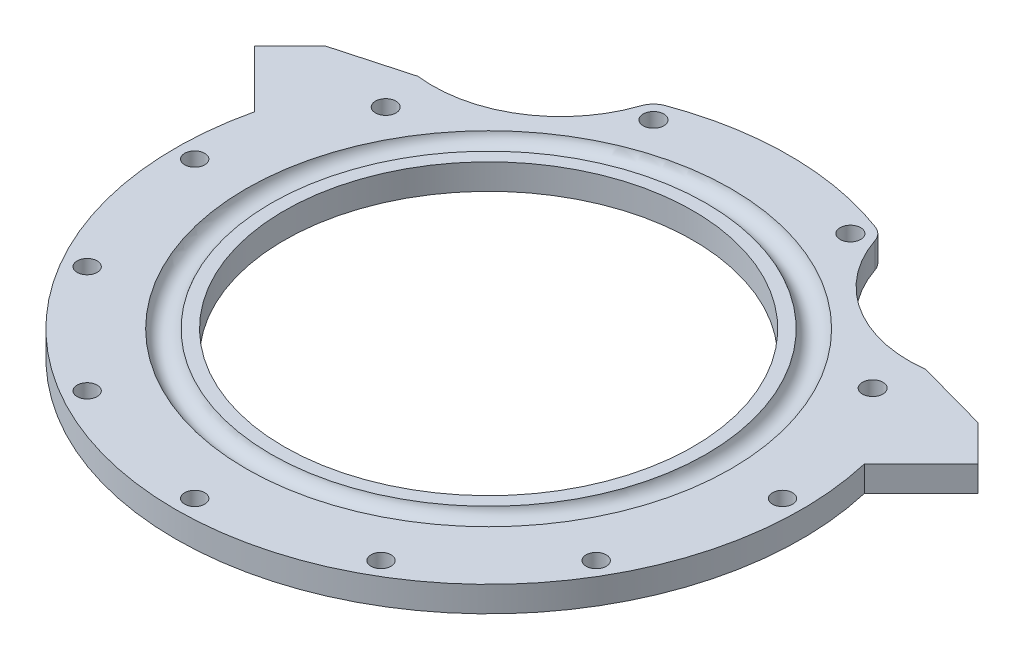
from build123d import *

# Parameters (mm, degrees)
SKETCH1_R           = 63.5
SKETCH1_R_2         = 50.8
BOSS_EXTRUDE1_DEPTH = 3.175
SKETCH2_R           = 3.175
SKETCH3_R           = 77.7875
SKETCH3_R_2         = 63.5
BOSS_EXTRUDE2_DEPTH = 6.35
SKETCH4_R           = 2.4892
CUT_EXTRUDE1_DEPTH  = 7.35
CIRPATTERN1_COUNT   = 12
BOSS_EXTRUDE3_DEPTH = 6.35
SKETCH6_R           = 31.75
CUT_EXTRUDE2_DEPTH  = 7.35
SKETCH7_R           = 2.5527
CUT_EXTRUDE3_DEPTH  = 7.35
BOSS_EXTRUDE4_DEPTH = 6.35
CUT_EXTRUDE4_DEPTH  = 7.35


with BuildPart() as part:
    # Sketch1 → Boss-Extrude1 (new body, symmetric)
    with BuildSketch(Plane(origin=(0, 0, 0), x_dir=(1, 0, 0), z_dir=(0, 1, 0))):
        Circle(SKETCH1_R)
        Circle(SKETCH1_R_2, mode=Mode.SUBTRACT)
    extrude(amount=BOSS_EXTRUDE1_DEPTH, both=True)

    # Sketch2 → Cut-Revolve1 (revolve, cut)
    with BuildSketch(Plane.XY):
        with Locations((57.15, 3.81)):
            Circle(SKETCH2_R)
    revolve(axis=Axis((0, 0, 0), (0, 1, 0)), mode=Mode.SUBTRACT)

    # Sketch3 → Boss-Extrude2 (add, through all)
    with BuildSketch(Plane.XZ.offset(3.175)):
        Circle(SKETCH3_R)
        Circle(SKETCH3_R_2, mode=Mode.SUBTRACT)
    extrude(amount=-BOSS_EXTRUDE2_DEPTH)

    # Sketch4 → Cut-Extrude1 (cut, through all)
    with BuildSketch(Plane(origin=(0, 3.175, 0), x_dir=(1, 0, 0), z_dir=(0, 1, 0))):
        with Locations((0, -73.025)):
            Circle(SKETCH4_R)
    cut_extrude1 = extrude(amount=-CUT_EXTRUDE1_DEPTH, mode=Mode.SUBTRACT)

    # CirPattern1: Cut-Extrude1 ×12 about axis, 5 skipped
    cirpattern1_axis = Axis((0, 0, 0), (0, 1, 0))
    add([cut_extrude1.rotate(cirpattern1_axis, i * 360 / CIRPATTERN1_COUNT) for i in range(1, CIRPATTERN1_COUNT) if i not in (4, 5, 6, 7, 8)], mode=Mode.SUBTRACT)

    # Sketch5 → Boss-Extrude3 (add, through all)
    with BuildSketch(Plane(origin=(0, 3.175, 0), x_dir=(1, 0, 0), z_dir=(0, 1, 0))):
        with BuildLine():
            Line((74.895357071, 21.013820344), (87.737123324, 33.855586598))
            Line((87.737123324, 33.855586598), (81.001931233, 40.590778688))
            Line((81.001931233, 40.590778688), (71.363979938, 30.952827393))
            ThreePointArc((71.363979938, 30.952827393), (73.298324543, 26.043248173), (74.895357071, 21.013820344))
        make_face()
        with BuildLine():
            Line((-71.363979938, 30.952827393), (-81.001931233, 40.590778688))
            Line((-81.001931233, 40.590778688), (-87.737123324, 33.855586598))
            Line((-87.737123324, 33.855586598), (-74.895357071, 21.013820344))
            ThreePointArc((-74.895357071, 21.013820344), (-73.298324543, 26.043248173), (-71.363979938, 30.952827393))
        make_face()
    extrude(amount=-BOSS_EXTRUDE3_DEPTH)

    # Sketch6 → Cut-Extrude2 (cut, through all)
    with BuildSketch(Plane(origin=(0, 3.175, 0), x_dir=(1, 0, 0), z_dir=(0, 1, 0))):
        with Locations((59.128754095, 77.058092601)):
            Circle(SKETCH6_R)
    cut_extrude2 = extrude(amount=-CUT_EXTRUDE2_DEPTH, mode=Mode.SUBTRACT)

    # Sketch7 → Cut-Extrude3 (cut, through all)
    with BuildSketch(Plane(origin=(0, 3.175, 0), x_dir=(1, 0, 0), z_dir=(0, 1, 0))):
        with Locations((-24.461985581, 65.426552419)):
            Circle(SKETCH7_R)
        with Locations((-60.491874454, 34.925)):
            Circle(SKETCH7_R)
        with Locations((24.461985581, 65.426552419)):
            Circle(SKETCH7_R)
        with Locations((60.491874454, 34.925)):
            Circle(SKETCH7_R)
    extrude(amount=-CUT_EXTRUDE3_DEPTH, mode=Mode.SUBTRACT)

    # Sketch9 → Boss-Extrude4 (add, through all)
    with BuildSketch(Plane(origin=(0, 3.175, 0), x_dir=(1, 0, 0), z_dir=(0, 1, 0))):
        Polygon((75.767612718, 17.611474078), (73.630311762, 19.748775035), (87.737123324, 33.855586598), (89.874424281, 31.718285641), align=None)
        Polygon((81.001931233, 40.590778688), (63.054974858, 45.551787033), (71.363979938, 30.952827393), align=None)
    boss_extrude4 = extrude(amount=-BOSS_EXTRUDE4_DEPTH)

    # Mirror1: Cut-Extrude2, Boss-Extrude4 across plane
    add(cut_extrude2.mirror(Plane(origin=(0, 0, 0), x_dir=(0, 0, 1), z_dir=(1, 0, 0))), mode=Mode.SUBTRACT)
    add(boss_extrude4.mirror(Plane(origin=(0, 0, 0), x_dir=(0, 0, 1), z_dir=(1, 0, 0))))

    # Sketch8 → Cut-Extrude4 (cut, through all)
    with BuildSketch(Plane.XZ.offset(3.175)):
        with BuildLine():
            ThreePointArc((-29.027902052, -66.958527944), (-27.924980023, -68.773522948), (-26.148609279, -69.937632415))
            ThreePointArc((-26.148609279, -69.937632415), (0, -74.666071244), (26.148609279, -69.937632415))
            ThreePointArc((26.148609279, -69.937632415), (27.924980023, -68.773522948), (29.027902052, -66.958527944))
            ThreePointArc((29.027902052, -66.958527944), (28.220438074, -69.795964761), (27.679819148, -72.696098714))
            ThreePointArc((27.679819148, -72.696098714), (0, -77.7875), (-27.679819148, -72.696098714))
            ThreePointArc((-27.679819148, -72.696098714), (-28.220438074, -69.795964761), (-29.027902052, -66.958527944))
        make_face()
    extrude(amount=-CUT_EXTRUDE4_DEPTH, mode=Mode.SUBTRACT)


solid = part.part
